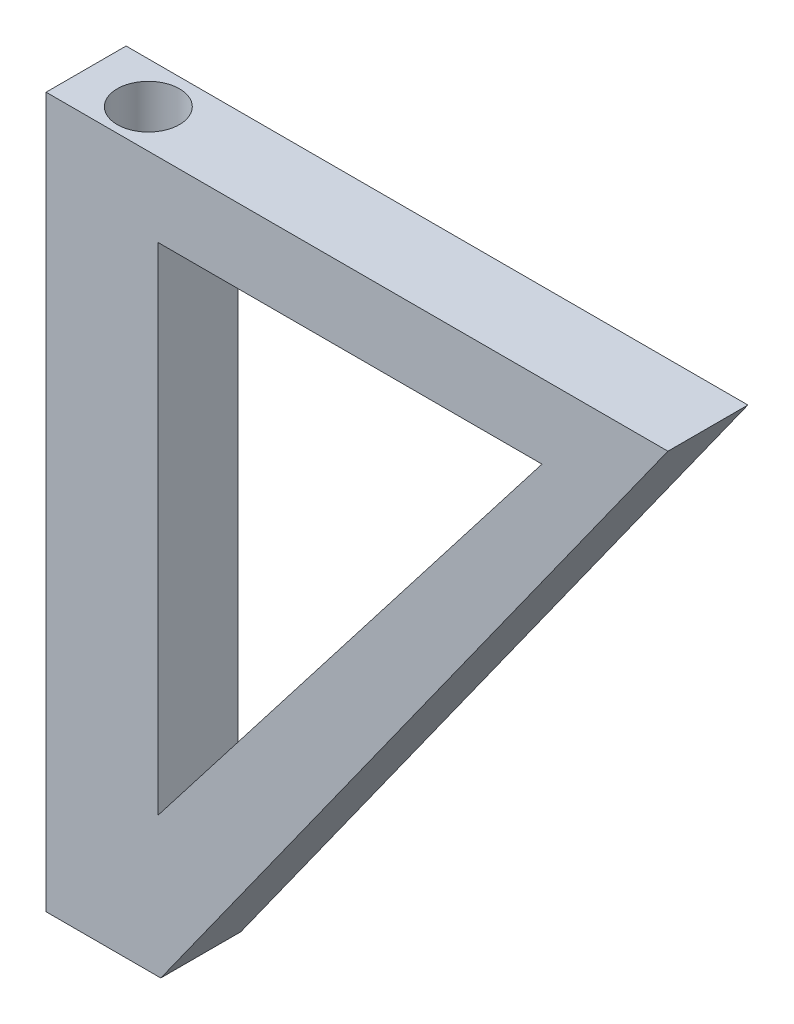
from build123d import *

# Parameters (mm, degrees)
BOSS_EXTRU_1_DEPTH      = 10
ESQUISSE2_R             = 3.889151143
ENL_V_MAT_EXTRU_1_DEPTH = 89.737541713
ENL_V_MAT_EXTRU_2_DEPTH = 11


with BuildPart() as part:
    # Esquisse1 → Boss.-Extru.1 (new body)
    with BuildSketch(Plane.XY):
        Polygon((0, 0), (77.738226815, 0), (14.337114468, -88.737541713), (0, -88.737541713), align=None)
    extrude(amount=BOSS_EXTRU_1_DEPTH)

    # Esquisse2 → Enlèv. mat.-Extru.1 (cut, through all)
    with BuildSketch(Plane(origin=(0, 0, 0), x_dir=(1, 0, 0), z_dir=(0, 1, 0))):
        with Locations((7.959936212, -5.179369155)):
            Circle(ESQUISSE2_R)
    extrude(amount=-ENL_V_MAT_EXTRU_1_DEPTH, mode=Mode.SUBTRACT)

    # Esquisse4 → Enlèv. mat.-Extru.2 (cut, through all)
    with BuildSketch(Plane.XY.offset(10)):
        Polygon((13.992554962, -9.272968918), (13.992554962, -71.289178), (61.99380154, -9.272968918), align=None)
    extrude(amount=-ENL_V_MAT_EXTRU_2_DEPTH, mode=Mode.SUBTRACT)


solid = part.part
